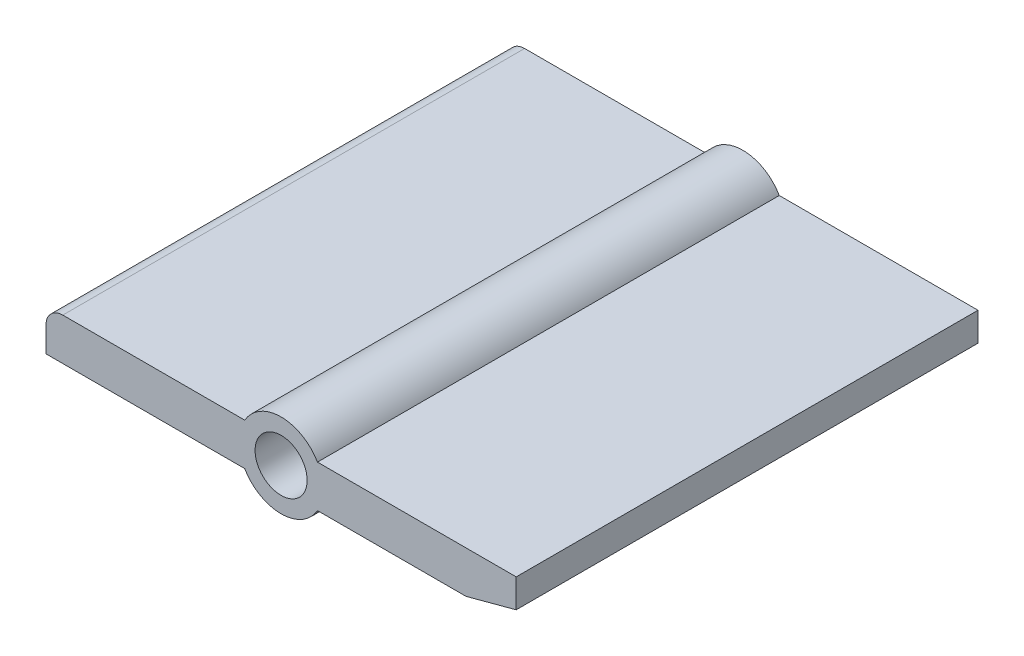
from build123d import *

# Parameters (mm, degrees)
SKETCH_1_R      = 1.55
EXTRUDE_1_DEPTH = 27.5


with BuildPart() as part:
    # 草图1 → 凸台-拉伸1 (new body)
    with BuildSketch(Plane.XY):
        with BuildLine():
            Line((2.165063509, 1.25), (14, 1.25))
            Line((14, 1.25), (14, -0.45))
            Line((14, -0.45), (11.014359354, -1.25))
            Line((11.014359354, -1.25), (2.165063509, -1.25))
            ThreePointArc((2.165063509, -1.25), (0, -2.5), (-2.165063509, -1.25))
            Line((-2.165063509, -1.25), (-14, -1.25))
            Line((-14, -1.25), (-14, 0.25))
            ThreePointArc((-14, 0.25), (-13.707106781, 0.957106781), (-13, 1.25))
            Line((-13, 1.25), (-2.165063509, 1.25))
            ThreePointArc((-2.165063509, 1.25), (0, 2.5), (2.165063509, 1.25))
        make_face()
        Circle(SKETCH_1_R, mode=Mode.SUBTRACT)
    extrude(amount=EXTRUDE_1_DEPTH)


solid = part.part
